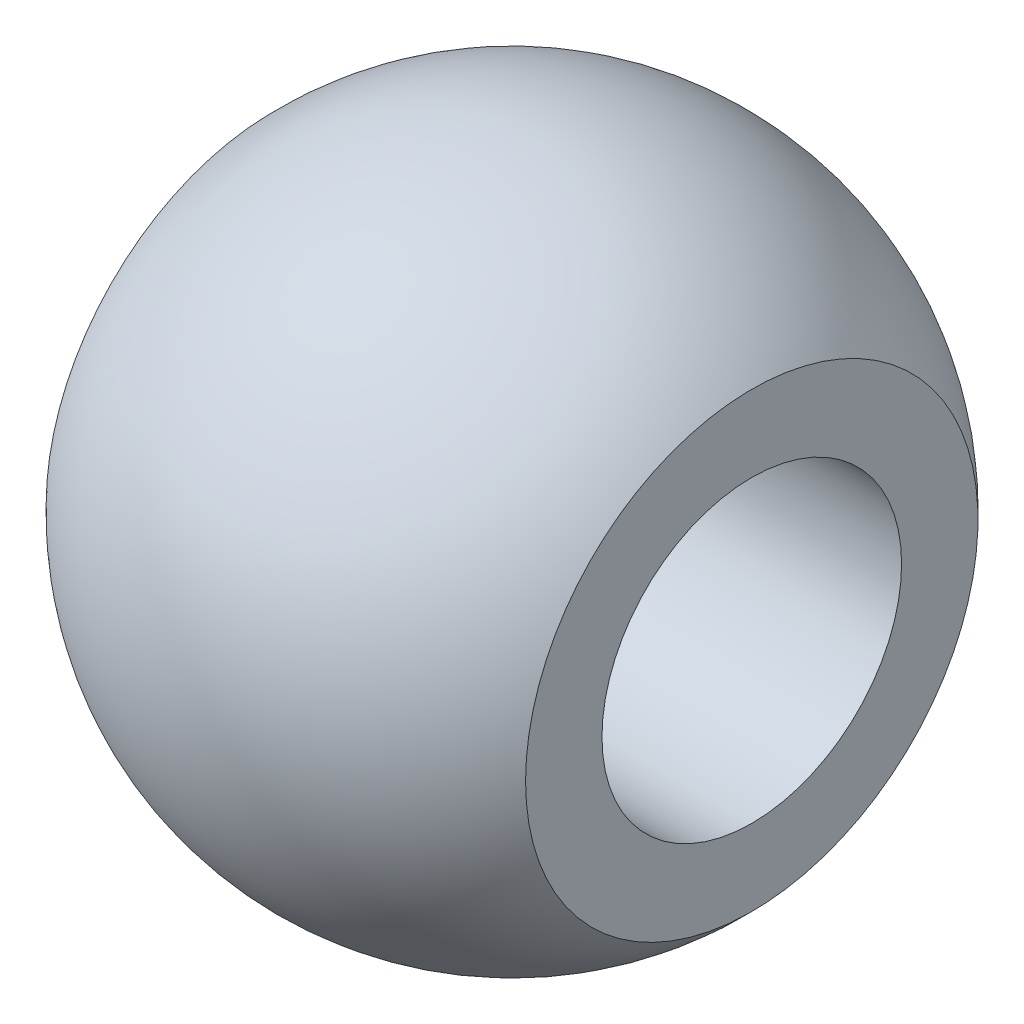
from build123d import *


with BuildPart() as part:
    # Sketch1 → Revolve1 (revolve)
    with BuildSketch(Plane.XY):
        with BuildLine():
            Line((-4, 3.774917218), (-4, 2.5))
            Line((-4, 2.5), (4, 2.5))
            Line((4, 2.5), (4, 3.774917218))
            ThreePointArc((4, 3.774917218), (0, 5.5), (-4, 3.774917218))
        make_face()
    revolve(axis=Axis((-6.07712766, 0, 0), (1, 0, 0)))


solid = part.part
